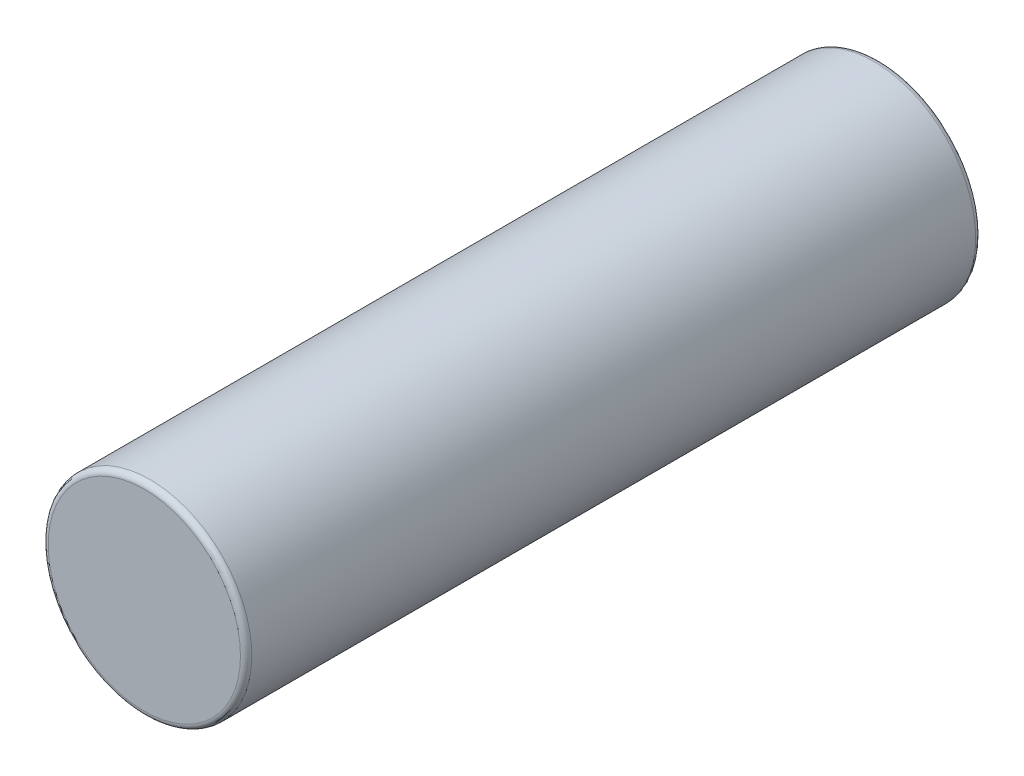
from build123d import *

# Parameters (mm, degrees)
SKETCH_1_R      = 9
EXTRUDE_1_DEPTH = 65
FILLET_1_R      = 0.5


with BuildPart() as part:
    # Эскиз1 → Бобышка-Вытянуть1 (new body)
    with BuildSketch(Plane.XY):
        Circle(SKETCH_1_R)
    extrude(amount=EXTRUDE_1_DEPTH)

    # Скругление1
    fillet_1_edges = [part.edges().sort_by_distance(p)[0] for p in [
        (-9, 0, 0),
        (-9, 0, 65),
    ]]
    fillet(fillet_1_edges, radius=FILLET_1_R)


solid = part.part
